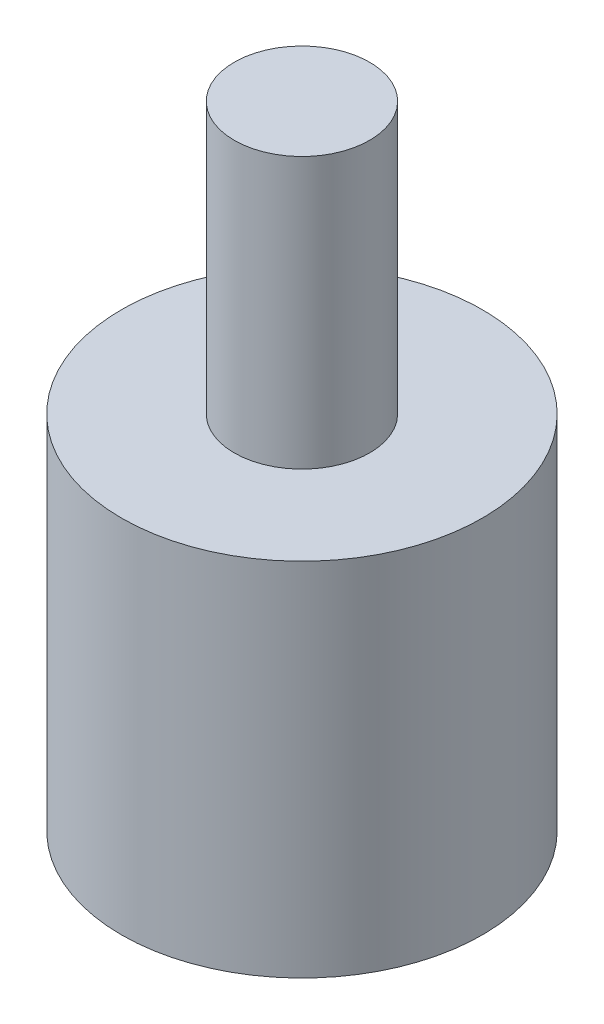
from build123d import *

# Parameters (mm, degrees)
SKETCH1_R           = 4
SKETCH1_R_2         = 1.5
BOSS_EXTRUDE1_DEPTH = 8
SKETCH2_R           = 1.5
BOSS_EXTRUDE2_DEPTH = 5
SKETCH3_R           = 1.5
BOSS_EXTRUDE3_DEPTH = 6


with BuildPart() as part:
    # Sketch1 → Boss-Extrude1 (new body)
    with BuildSketch(Plane(origin=(0, 0, 0), x_dir=(1, 0, 0), z_dir=(0, 1, 0))):
        Circle(SKETCH1_R)
        Circle(SKETCH1_R_2, mode=Mode.SUBTRACT)
    extrude(amount=BOSS_EXTRUDE1_DEPTH)

    # Sketch2 → Boss-Extrude2 (add)
    with BuildSketch(Plane(origin=(0, 8, 0), x_dir=(1, 0, 0), z_dir=(0, 1, 0))):
        Circle(SKETCH2_R)
    extrude(amount=-BOSS_EXTRUDE2_DEPTH)

    # Sketch3 → Boss-Extrude3 (add)
    with BuildSketch(Plane(origin=(0, 8, 0), x_dir=(1, 0, 0), z_dir=(0, 1, 0))):
        Circle(SKETCH3_R)
    extrude(amount=BOSS_EXTRUDE3_DEPTH)


solid = part.part
